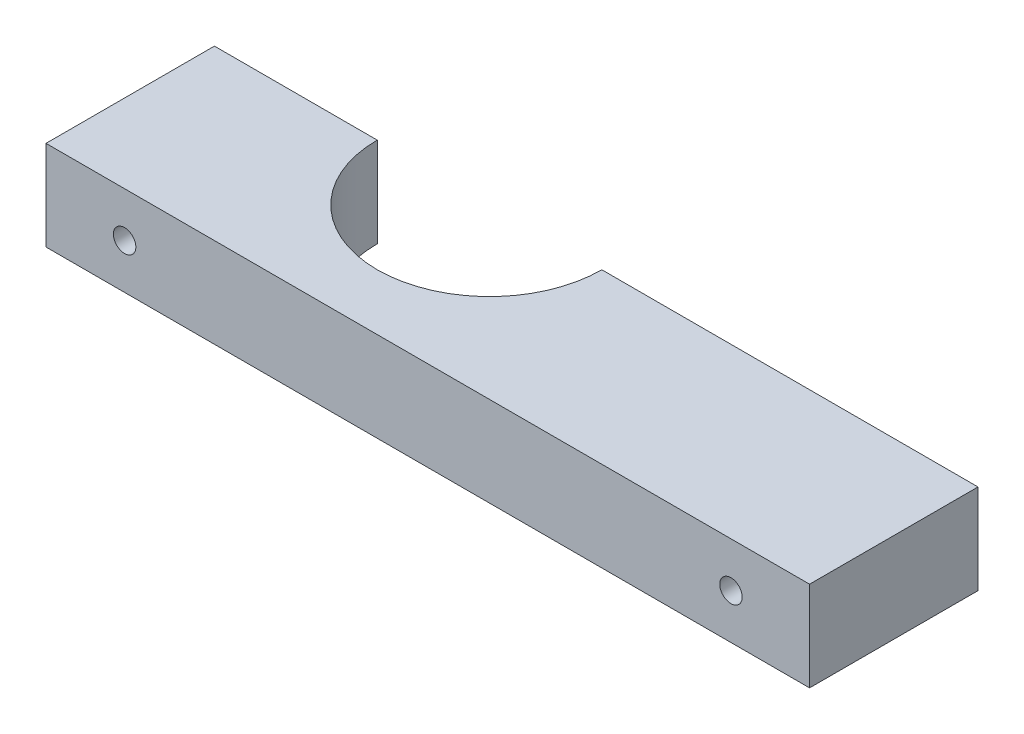
from build123d import *

# Parameters (mm, degrees)
BOSS_EXTRUDE1_DEPTH = 8
SKETCH2_R           = 1
CUT_EXTRUDE1_DEPTH  = 16.340604027


with BuildPart() as part:
    # Sketch1 → Boss-Extrude1 (new body)
    with BuildSketch(Plane(origin=(0, 0, 0), x_dir=(1, 0, 0), z_dir=(0, 1, 0))):
        with BuildLine():
            Line((2.649328859, -0.340604027), (36.149328859, -0.340604027))
            Line((36.149328859, -0.340604027), (36.149328859, -15.340604027))
            Line((36.149328859, -15.340604027), (-31.850671141, -15.340604027))
            Line((-31.850671141, -15.340604027), (-31.850671141, -0.340604027))
            Line((-31.850671141, -0.340604027), (-17.350671141, -0.340604027))
            ThreePointArc((-17.350671141, -0.340604027), (-7.350671141, -10.340604027), (2.649328859, -0.340604027))
        make_face()
    extrude(amount=BOSS_EXTRUDE1_DEPTH)

    # Sketch2 → Cut-Extrude1 (cut, through all)
    with BuildSketch(Plane.XY):
        with Locations((-24.850671141, 4)):
            Circle(SKETCH2_R)
        with Locations((29.149328859, 4)):
            Circle(SKETCH2_R)
    extrude(amount=CUT_EXTRUDE1_DEPTH, mode=Mode.SUBTRACT)


solid = part.part
